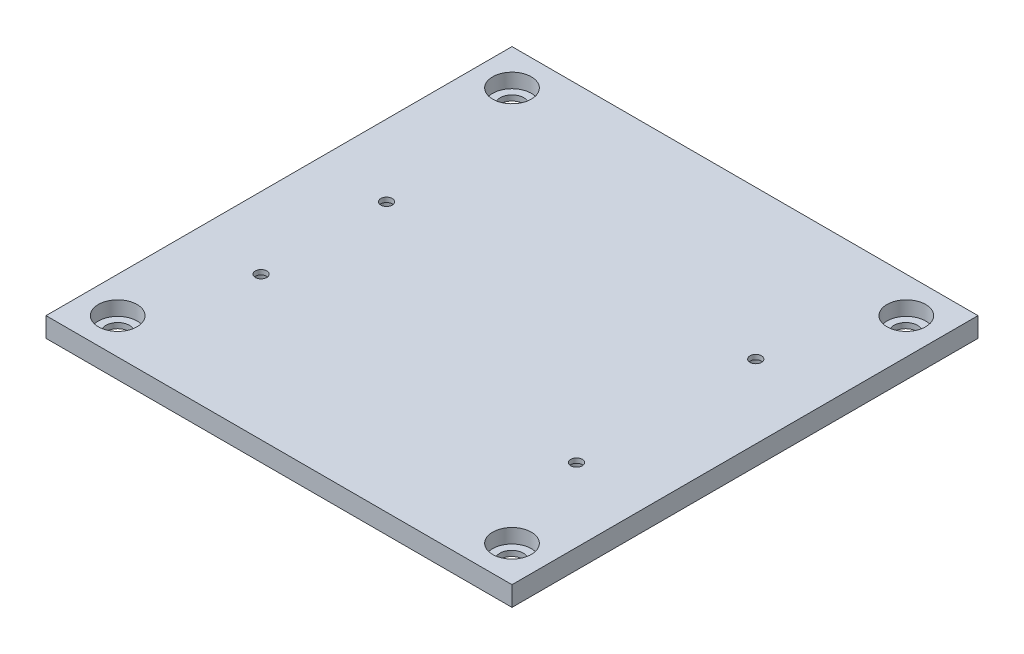
from build123d import *

# Parameters (mm, degrees)
SKETCH_1_W           = 130
SKETCH_1_H           = 130
EXTRUDE_1_DEPTH      = 5.5
SKETCH_4_R           = 5.4
CUT_EXTRUDE_7_DEPTH  = 4
SKETCH_6_R           = 3.3
CUT_EXTRUDE_8_DEPTH  = 1.5
SKETCH_7_R           = 3.1
CUT_EXTRUDE_9_DEPTH  = 4.2
SKETCH_8_R           = 1.6
CUT_EXTRUDE_10_DEPTH = 2.3


with BuildPart() as part:
    # 草图1 → 凸台-拉伸1 (new body)
    with BuildSketch(Plane(origin=(0, 0, 0), x_dir=(1, 0, 0), z_dir=(0, 1, 0))):
        with Locations((65, 65)):
            Rectangle(SKETCH_1_W, SKETCH_1_H)
    extrude(amount=EXTRUDE_1_DEPTH)

    # 草图4 → 切除-拉伸7 (cut)
    with BuildSketch(Plane(origin=(0, 5.5, 0), x_dir=(1, 0, 0), z_dir=(0, 1, 0))):
        with Locations((10, 120)):
            Circle(SKETCH_4_R)
        with Locations((120, 120)):
            Circle(SKETCH_4_R)
        with Locations((10, 10)):
            Circle(SKETCH_4_R)
        with Locations((120, 10)):
            Circle(SKETCH_4_R)
    extrude(amount=-CUT_EXTRUDE_7_DEPTH, mode=Mode.SUBTRACT)

    # 草图6 → 切除-拉伸8 (cut)
    with BuildSketch(Plane(origin=(0, 1.5, 0), x_dir=(1, 0, 0), z_dir=(0, 1, 0))):
        with Locations((10, 120)):
            Circle(SKETCH_6_R)
        with Locations((119.916006429, 119.916006429)):
            Circle(SKETCH_6_R)
        with Locations((10, 10)):
            Circle(SKETCH_6_R)
        with Locations((120, 9.916006429)):
            Circle(SKETCH_6_R)
    extrude(amount=-CUT_EXTRUDE_8_DEPTH, mode=Mode.SUBTRACT)

    # 草图7 → 切除-拉伸9 (cut)
    with BuildSketch(Plane.XZ):
        with Locations((20, -40)):
            Circle(SKETCH_7_R)
        with Locations((20, -75)):
            Circle(SKETCH_7_R)
        with Locations((109.5, -38.5)):
            Circle(SKETCH_7_R)
        with Locations((109.5, -88.5)):
            Circle(SKETCH_7_R)
    extrude(amount=-CUT_EXTRUDE_9_DEPTH, mode=Mode.SUBTRACT)

    # 草图8 → 切除-拉伸10 (cut, through all)
    with BuildSketch(Plane.XZ.offset(-4.2)):
        with Locations((20, -40)):
            Circle(SKETCH_8_R)
        with Locations((20, -75)):
            Circle(SKETCH_8_R)
        with Locations((109.5, -38.5)):
            Circle(SKETCH_8_R)
        with Locations((109.5, -88.5)):
            Circle(SKETCH_8_R)
    extrude(amount=-CUT_EXTRUDE_10_DEPTH, mode=Mode.SUBTRACT)


solid = part.part
